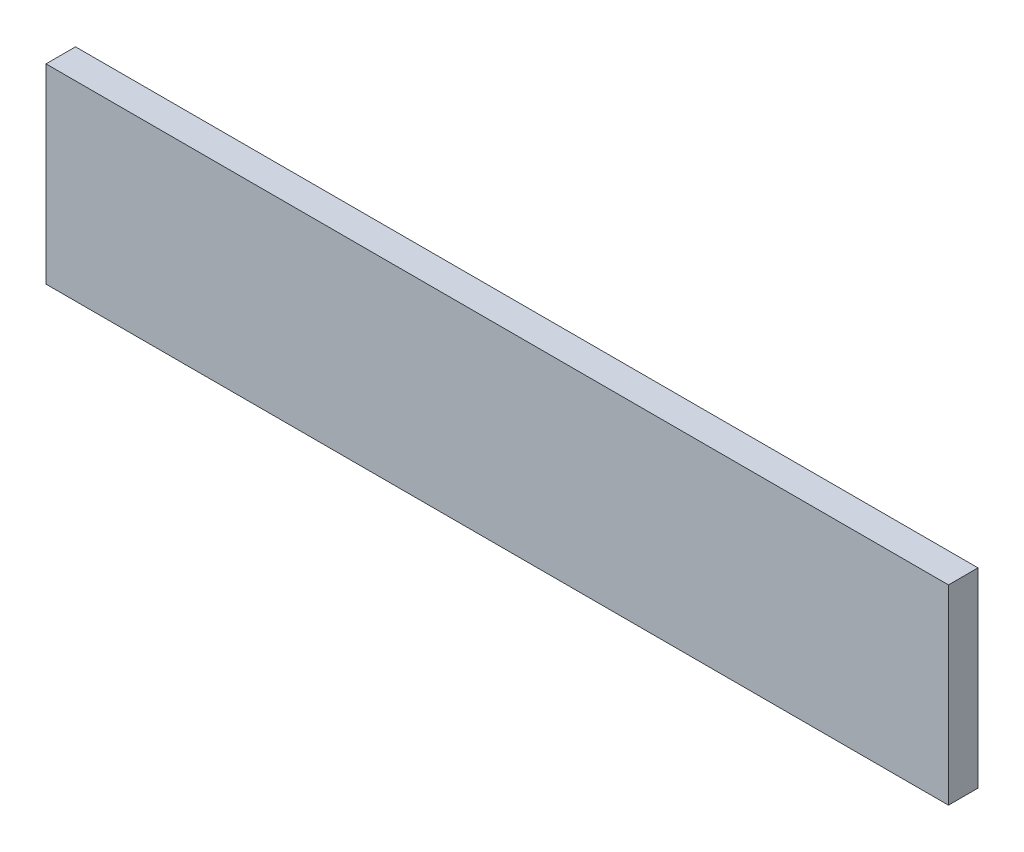
from build123d import *

# Parameters (mm, degrees)
ESBO_O1_W                = 107
ESBO_O1_H                = 22.62
RESSALTO_EXTRUS_O1_DEPTH = 3.5
ESBO_O1_4_R              = 3.5
RESSALTO_EXTRUS_O2_DEPTH = 2
ESBO_O1_7_R              = 1.5
CORTE_EXTRUS_O1_DEPTH    = 2


with BuildPart() as part:
    # Esbo_o1 → Ressalto-extrus_o1 (new body)
    with BuildSketch(Plane.XY):
        with Locations((12.82231405, 21.961694215)):
            Rectangle(ESBO_O1_W, ESBO_O1_H)
    extrude(amount=RESSALTO_EXTRUS_O1_DEPTH)

    # Esbo_o1_4 → Ressalto-extrus_o2 (add)
    with BuildSketch(Plane.XY):
        with Locations((14.32231405, 17.551694215)):
            Circle(ESBO_O1_4_R)
        with Locations((32.32231405, 17.551694215)):
            Circle(ESBO_O1_4_R)
        with Locations((50.32231405, 17.551694215)):
            Circle(ESBO_O1_4_R)
    extrude(amount=-RESSALTO_EXTRUS_O2_DEPTH)

    # Esbo_o1_7 → Corte-extrus_o1 (cut)
    with BuildSketch(Plane.XY):
        with Locations((14.32231405, 17.551694215)):
            Circle(ESBO_O1_7_R)
        with Locations((32.32231405, 17.551694215)):
            Circle(ESBO_O1_7_R)
        with Locations((50.32231405, 17.551694215)):
            Circle(ESBO_O1_7_R)
    extrude(amount=-CORTE_EXTRUS_O1_DEPTH, mode=Mode.SUBTRACT)


solid = part.part
